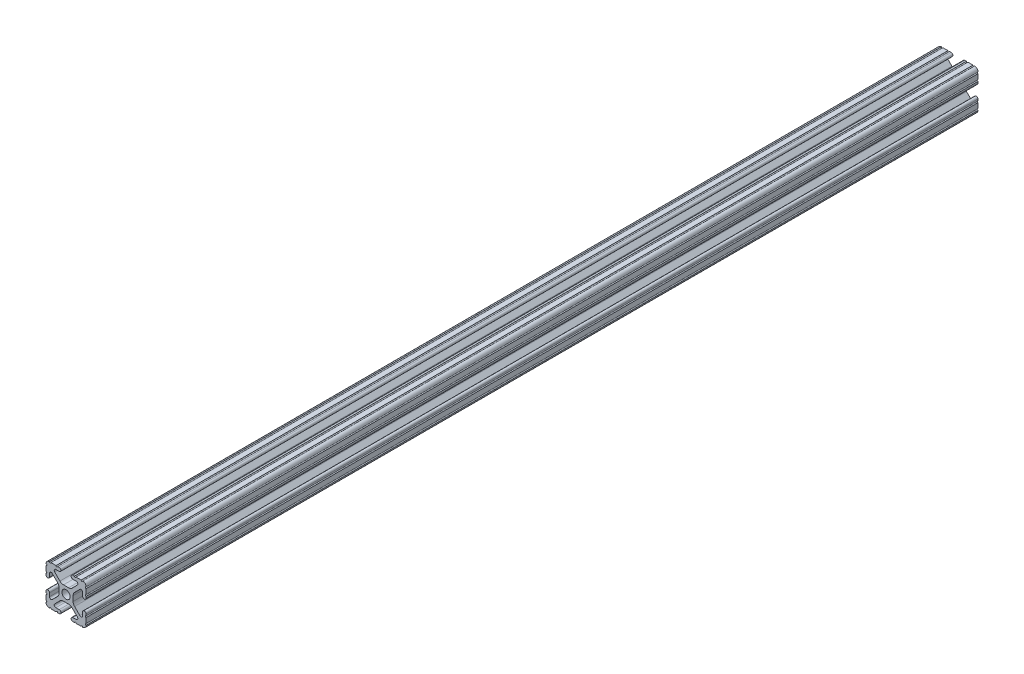
from build123d import *

# Parameters (mm, degrees)
SKETCH1_R           = 2.6035
BOSS_EXTRUDE1_DEPTH = 565.15


with BuildPart() as part:
    # Sketch1 → Boss-Extrude1 (new body)
    with BuildSketch(Plane.XY):
        with BuildLine():
            Line((-12.7, -6.3330836), (-12.7, -9.5504))
            ThreePointArc((-12.7, -9.5504), (-12.192000006, -10.058323491), (-12.699846982, -10.566399977))
            ThreePointArc((-12.699846982, -10.566399977), (-12.082522516, -12.082522516), (-10.566399977, -12.699846982))
            ThreePointArc((-10.566399977, -12.699846982), (-10.058323491, -12.192000006), (-9.5504, -12.7))
            Line((-9.5504, -12.7), (-6.3330836, -12.7))
            ThreePointArc((-6.3330836, -12.7), (-5.8250836, -12.192), (-5.3170836, -12.7))
            Line((-5.3170836, -12.7), (-4.343399971, -12.7))
            ThreePointArc((-4.343399971, -12.7), (-3.238499971, -11.5951), (-4.343399971, -10.4902))
            Line((-4.343399971, -10.4902), (-6.474794456, -10.4902))
            ThreePointArc((-6.474794456, -10.4902), (-7.413456061, -9.863006367), (-7.193214945, -8.75577951))
            Line((-7.193214945, -8.75577951), (-3.863171405, -5.42573597))
            ThreePointArc((-3.863171405, -5.42573597), (-2.833127272, -4.737482484), (-1.618107374, -4.4958))
            Line((-1.618107374, -4.4958), (1.618107374, -4.4958))
            ThreePointArc((1.618107374, -4.4958), (2.833127272, -4.737482484), (3.863171405, -5.42573597))
            Line((3.863171405, -5.42573597), (7.193214945, -8.75577951))
            ThreePointArc((7.193214945, -8.75577951), (7.413456061, -9.863006367), (6.474794456, -10.4902))
            Line((6.474794456, -10.4902), (4.3434, -10.4902))
            ThreePointArc((4.3434, -10.4902), (3.2385, -11.5951), (4.3434, -12.7))
            Line((4.3434, -12.7), (5.3170836, -12.7))
            ThreePointArc((5.3170836, -12.7), (5.8250836, -12.192), (6.3330836, -12.7))
            Line((6.3330836, -12.7), (9.5504, -12.7))
            ThreePointArc((9.5504, -12.7), (10.058323491, -12.192000006), (10.566399977, -12.699846982))
            ThreePointArc((10.566399977, -12.699846982), (12.082522516, -12.082522516), (12.699846982, -10.566399977))
            ThreePointArc((12.699846982, -10.566399977), (12.192000006, -10.058323491), (12.7, -9.5504))
            Line((12.7, -9.5504), (12.7, -6.3330836))
            ThreePointArc((12.7, -6.3330836), (12.192, -5.8250836), (12.7, -5.3170836))
            Line((12.7, -5.3170836), (12.7, -4.343399971))
            ThreePointArc((12.7, -4.343399971), (11.5951, -3.238499971), (10.4902, -4.343399971))
            Line((10.4902, -4.343399971), (10.4902, -6.474794456))
            ThreePointArc((10.4902, -6.474794456), (9.863006367, -7.413456061), (8.75577951, -7.193214945))
            Line((8.75577951, -7.193214945), (5.42573597, -3.863171405))
            ThreePointArc((5.42573597, -3.863171405), (4.737482484, -2.833127272), (4.4958, -1.618107374))
            Line((4.4958, -1.618107374), (4.4958, 1.618107374))
            ThreePointArc((4.4958, 1.618107374), (4.737482484, 2.833127272), (5.42573597, 3.863171405))
            Line((5.42573597, 3.863171405), (8.75577951, 7.193214945))
            ThreePointArc((8.75577951, 7.193214945), (9.863006367, 7.413456061), (10.4902, 6.474794456))
            Line((10.4902, 6.474794456), (10.4902, 4.3434))
            ThreePointArc((10.4902, 4.3434), (11.5951, 3.2385), (12.7, 4.3434))
            Line((12.7, 4.3434), (12.7, 5.3170836))
            ThreePointArc((12.7, 5.3170836), (12.192, 5.8250836), (12.7, 6.3330836))
            Line((12.7, 6.3330836), (12.7, 9.5504))
            ThreePointArc((12.7, 9.5504), (12.192000006, 10.058323491), (12.699846982, 10.566399977))
            ThreePointArc((12.699846982, 10.566399977), (12.082522516, 12.082522516), (10.566399977, 12.699846982))
            ThreePointArc((10.566399977, 12.699846982), (10.058323491, 12.192000006), (9.5504, 12.7))
            Line((9.5504, 12.7), (6.3330836, 12.7))
            ThreePointArc((6.3330836, 12.7), (5.8250836, 12.192), (5.3170836, 12.7))
            Line((5.3170836, 12.7), (4.343399971, 12.7))
            ThreePointArc((4.343399971, 12.7), (3.238499971, 11.5951), (4.343399971, 10.4902))
            Line((4.343399971, 10.4902), (6.474794456, 10.4902))
            ThreePointArc((6.474794456, 10.4902), (7.413456061, 9.863006367), (7.193214945, 8.75577951))
            Line((7.193214945, 8.75577951), (3.863171405, 5.42573597))
            ThreePointArc((3.863171405, 5.42573597), (2.833127272, 4.737482484), (1.618107374, 4.4958))
            Line((1.618107374, 4.4958), (-1.618107374, 4.4958))
            ThreePointArc((-1.618107374, 4.4958), (-2.833127272, 4.737482484), (-3.863171405, 5.42573597))
            Line((-3.863171405, 5.42573597), (-7.193214945, 8.75577951))
            ThreePointArc((-7.193214945, 8.75577951), (-7.413456061, 9.863006367), (-6.474794456, 10.4902))
            Line((-6.474794456, 10.4902), (-4.3434, 10.4902))
            ThreePointArc((-4.3434, 10.4902), (-3.2385, 11.5951), (-4.3434, 12.7))
            Line((-4.3434, 12.7), (-5.3170836, 12.7))
            ThreePointArc((-5.3170836, 12.7), (-5.8250836, 12.192), (-6.3330836, 12.7))
            Line((-6.3330836, 12.7), (-9.5504, 12.7))
            ThreePointArc((-9.5504, 12.7), (-10.058323491, 12.192000006), (-10.566399977, 12.699846982))
            ThreePointArc((-10.566399977, 12.699846982), (-12.082522516, 12.082522516), (-12.699846982, 10.566399977))
            ThreePointArc((-12.699846982, 10.566399977), (-12.192000006, 10.058323491), (-12.7, 9.5504))
            Line((-12.7, 9.5504), (-12.7, 6.3330836))
            ThreePointArc((-12.7, 6.3330836), (-12.192, 5.8250836), (-12.7, 5.3170836))
            Line((-12.7, 5.3170836), (-12.7, 4.343399971))
            ThreePointArc((-12.7, 4.343399971), (-11.5951, 3.238499971), (-10.4902, 4.343399971))
            Line((-10.4902, 4.343399971), (-10.4902, 6.474794456))
            ThreePointArc((-10.4902, 6.474794456), (-9.863006367, 7.413456061), (-8.75577951, 7.193214945))
            Line((-8.75577951, 7.193214945), (-5.42573597, 3.863171405))
            ThreePointArc((-5.42573597, 3.863171405), (-4.737482484, 2.833127272), (-4.4958, 1.618107374))
            Line((-4.4958, 1.618107374), (-4.4958, -1.618107374))
            ThreePointArc((-4.4958, -1.618107374), (-4.737482484, -2.833127272), (-5.42573597, -3.863171405))
            Line((-5.42573597, -3.863171405), (-8.75577951, -7.193214945))
            ThreePointArc((-8.75577951, -7.193214945), (-9.863006367, -7.413456061), (-10.4902, -6.474794456))
            Line((-10.4902, -6.474794456), (-10.4902, -4.3434))
            ThreePointArc((-10.4902, -4.3434), (-11.5951, -3.2385), (-12.7, -4.3434))
            Line((-12.7, -4.3434), (-12.7, -5.3170836))
            ThreePointArc((-12.7, -5.3170836), (-12.192, -5.8250836), (-12.7, -6.3330836))
        make_face()
        Circle(SKETCH1_R, mode=Mode.SUBTRACT)
    extrude(amount=-BOSS_EXTRUDE1_DEPTH)


solid = part.part
